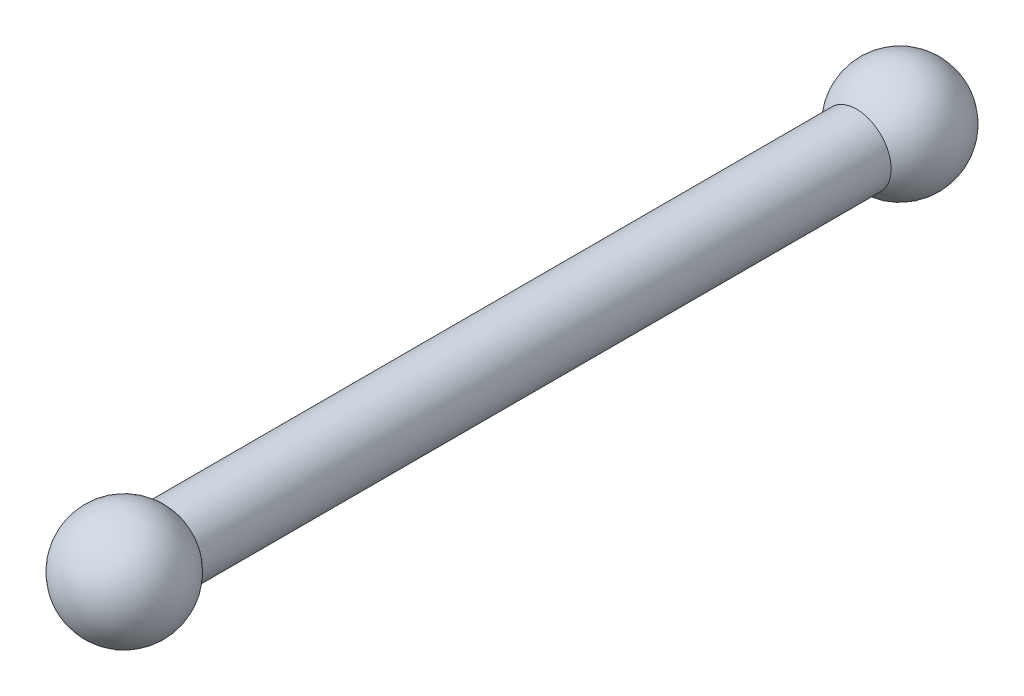
from build123d import *


with BuildPart() as part:
    # Sketch1 → Revolve5 (revolve)
    with BuildSketch(Plane(origin=(0, 0, 0), x_dir=(0, 0, -1), z_dir=(1, 0, 0))):
        with BuildLine():
            Line((9.913934322, 7.9375), (167.886065678, 7.9375))
            ThreePointArc((167.886065678, 7.9375), (182.006128511, 11.983258444), (190.5, 0))
            Line((190.5, 0), (165.1, 0))
            ThreePointArc((165.1, 0), (165.550040167, 3.350893028), (166.86826521, 6.4643))
            Line((166.86826521, 6.4643), (10.93173479, 6.4643))
            ThreePointArc((10.93173479, 6.4643), (12.249959833, 3.350893028), (12.7, 0))
            Line((12.7, 0), (-12.7, 0))
            ThreePointArc((-12.7, 0), (-4.206128511, 11.983258444), (9.913934322, 7.9375))
        make_face()
    revolve(axis=Axis((0, 0, 12.7), (0, 0, -1)))


solid = part.part
